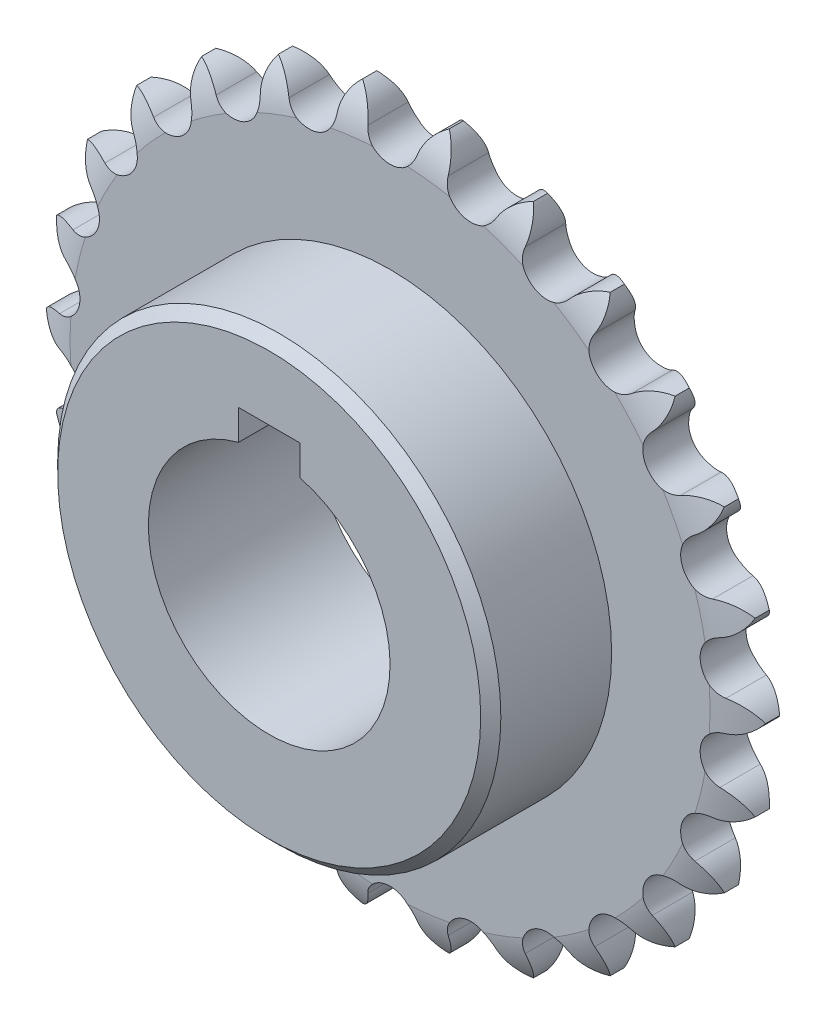
from build123d import *

# Parameters (mm, degrees)
SKETCH1_R           = 19.05
BOSS_EXTRUDE1_DEPTH = 3.6155
SKETCH2_W           = 19.05
SKETCH2_H           = 15.875
SKETCH3_W           = 9.65
SKETCH3_H           = 4.76
CUT_EXTRUDE1_DEPTH  = 85.080931
CHAMFER2_SIZE       = 1.5875
SCALE_1_SCALE       = 0.5
SCALE_2_SCALE       = 2
SCALE_3_SCALE       = 0.111111111


with BuildPart() as part:
    # Sketch1 → Boss-Extrude1 (new, symmetric)
    with BuildSketch(Plane.XY):
        with BuildLine():
            ThreePointArc((6.832203091, 56.268254805), (4.963717297, 54.655608899), (3.929721647, 52.414466562))
            ThreePointArc((3.929721647, 52.414466562), (0, 49.2633), (-3.929721647, 52.414466562))
            ThreePointArc((-3.929721647, 52.414466562), (-4.963717297, 54.655608899), (-6.832203091, 56.268254805))
            ThreePointArc((-6.832203091, 56.268254805), (-8.260462658, 54.25531154), (-8.728071806, 51.831841369))
            ThreePointArc((-8.728071806, 51.831841369), (-11.789479364, 47.831798034), (-16.359133961, 49.950953477))
            ThreePointArc((-16.359133961, 49.950953477), (-17.899424044, 51.879520935), (-20.099546463, 52.998148363))
            ThreePointArc((-20.099546463, 52.998148363), (-21.004574548, 50.701892683), (-20.87862145, 48.236937958))
            ThreePointArc((-20.87862145, 48.236937958), (-22.893797041, 43.620485829), (-27.837812873, 44.58447254))
            ThreePointArc((-27.837812873, 44.58447254), (-29.794881328, 46.088383789), (-32.198777254, 46.647982178))
            ThreePointArc((-32.198777254, 46.647982178), (-32.527976914, 44.201864118), (-31.815781507, 41.838679046))
            ThreePointArc((-31.815781507, 41.838679046), (-32.66761045, 36.87410954), (-37.698659287, 36.626904117))
            ThreePointArc((-37.698659287, 36.626904117), (-39.958768409, 37.618757301), (-42.426732148, 37.586804827))
            ThreePointArc((-42.426732148, 37.586804827), (-42.160971496, 35.132983877), (-40.903923988, 33.008908185))
            ThreePointArc((-40.903923988, 33.008908185), (-40.542901081, 27.984744038), (-45.368596652, 26.54071316))
            ThreePointArc((-45.368596652, 26.54071316), (-47.800397114, 26.962865377), (-50.188999585, 26.341219003))
            ThreePointArc((-50.188999585, 26.341219003), (-49.343723664, 24.022302317), (-47.614879086, 22.260779564))
            ThreePointArc((-47.614879086, 22.260779564), (-46.061985668, 17.469006932), (-50.401876088, 14.912072425))
            ThreePointArc((-50.401876088, 14.912072425), (-52.864040486, 14.739989724), (-55.034464796, 13.564777276))
            ThreePointArc((-55.034464796, 13.564777276), (-53.658797969, 11.515531863), (-51.558630485, 10.218935348))
            ThreePointArc((-51.558630485, 10.218935348), (-48.904115077, 5.93803464), (-52.505981689, 2.416796245))
            ThreePointArc((-52.505981689, 2.416796245), (-54.855417978, 1.660479445), (-56.681526955, 0))
            ThreePointArc((-56.681526955, 0), (-54.855417978, -1.660479445), (-52.505981689, -2.416796245))
            ThreePointArc((-52.505981689, -2.416796245), (-48.904115077, -5.93803464), (-51.558630485, -10.218935348))
            ThreePointArc((-51.558630485, -10.218935348), (-53.658797969, -11.515531863), (-55.034464796, -13.564777276))
            ThreePointArc((-55.034464796, -13.564777276), (-52.864040486, -14.739989724), (-50.401876088, -14.912072425))
            ThreePointArc((-50.401876088, -14.912072425), (-46.061985668, -17.469006932), (-47.614879086, -22.260779564))
            ThreePointArc((-47.614879086, -22.260779564), (-49.343723664, -24.022302317), (-50.188999585, -26.341219003))
            ThreePointArc((-50.188999585, -26.341219003), (-47.800397114, -26.962865377), (-45.368596652, -26.54071316))
            ThreePointArc((-45.368596652, -26.54071316), (-40.542901081, -27.984744038), (-40.903923988, -33.008908185))
            ThreePointArc((-40.903923988, -33.008908185), (-42.160971496, -35.132983877), (-42.426732148, -37.586804827))
            ThreePointArc((-42.426732148, -37.586804827), (-39.958768409, -37.618757301), (-37.698659287, -36.626904117))
            ThreePointArc((-37.698659287, -36.626904117), (-32.66761045, -36.87410954), (-31.815781507, -41.838679046))
            ThreePointArc((-31.815781507, -41.838679046), (-32.527976914, -44.201864118), (-32.198777254, -46.647982178))
            ThreePointArc((-32.198777254, -46.647982178), (-29.794881328, -46.088383789), (-27.837812873, -44.58447254))
            ThreePointArc((-27.837812873, -44.58447254), (-22.893797041, -43.620485829), (-20.87862145, -48.236937958))
            ThreePointArc((-20.87862145, -48.236937958), (-21.004574548, -50.701892683), (-20.099546463, -52.998148363))
            ThreePointArc((-20.099546463, -52.998148363), (-17.899424044, -51.879520935), (-16.359133961, -49.950953477))
            ThreePointArc((-16.359133961, -49.950953477), (-11.789479364, -47.831798034), (-8.728071806, -51.831841369))
            ThreePointArc((-8.728071806, -51.831841369), (-8.260462658, -54.25531154), (-6.832203091, -56.268254805))
            ThreePointArc((-6.832203091, -56.268254805), (-4.963717297, -54.655608899), (-3.929721647, -52.414466562))
            ThreePointArc((-3.929721647, -52.414466562), (0, -49.2633), (3.929721647, -52.414466562))
            ThreePointArc((3.929721647, -52.414466562), (4.963717297, -54.655608899), (6.832203091, -56.268254805))
            ThreePointArc((6.832203091, -56.268254805), (8.260462658, -54.25531154), (8.728071806, -51.831841369))
            ThreePointArc((8.728071806, -51.831841369), (11.789479365, -47.831798034), (16.359133961, -49.950953477))
            ThreePointArc((16.359133961, -49.950953477), (17.899424044, -51.879520935), (20.099546463, -52.998148363))
            ThreePointArc((20.099546463, -52.998148363), (21.004574548, -50.701892683), (20.87862145, -48.236937958))
            ThreePointArc((20.87862145, -48.236937958), (22.893797041, -43.620485829), (27.837812873, -44.58447254))
            ThreePointArc((27.837812873, -44.58447254), (29.794881328, -46.088383789), (32.198777254, -46.647982178))
            ThreePointArc((32.198777254, -46.647982178), (32.527976914, -44.201864118), (31.815781507, -41.838679046))
            ThreePointArc((31.815781507, -41.838679046), (32.66761045, -36.87410954), (37.698659287, -36.626904117))
            ThreePointArc((37.698659287, -36.626904117), (39.958768409, -37.618757301), (42.426732148, -37.586804827))
            ThreePointArc((42.426732148, -37.586804827), (42.160971496, -35.132983877), (40.903923988, -33.008908185))
            ThreePointArc((40.903923988, -33.008908185), (40.542901081, -27.984744038), (45.368596652, -26.54071316))
            ThreePointArc((45.368596652, -26.54071316), (47.800397114, -26.962865377), (50.188999585, -26.341219003))
            ThreePointArc((50.188999585, -26.341219003), (49.343723664, -24.022302317), (47.614879086, -22.260779564))
            ThreePointArc((47.614879086, -22.260779564), (46.061985668, -17.469006932), (50.401876088, -14.912072425))
            ThreePointArc((50.401876088, -14.912072425), (52.864040486, -14.739989724), (55.034464796, -13.564777276))
            ThreePointArc((55.034464796, -13.564777276), (53.658797969, -11.515531863), (51.558630485, -10.218935348))
            ThreePointArc((51.558630485, -10.218935348), (48.904115077, -5.93803464), (52.505981689, -2.416796245))
            ThreePointArc((52.505981689, -2.416796245), (54.855417978, -1.660479445), (56.681526955, 0))
            ThreePointArc((56.681526955, 0), (54.855417978, 1.660479445), (52.505981689, 2.416796245))
            ThreePointArc((52.505981689, 2.416796245), (48.904115077, 5.93803464), (51.558630485, 10.218935348))
            ThreePointArc((51.558630485, 10.218935348), (53.658797969, 11.515531863), (55.034464796, 13.564777276))
            ThreePointArc((55.034464796, 13.564777276), (52.864040486, 14.739989724), (50.401876088, 14.912072425))
            ThreePointArc((50.401876088, 14.912072425), (46.061985668, 17.469006932), (47.614879086, 22.260779564))
            ThreePointArc((47.614879086, 22.260779564), (49.343723664, 24.022302317), (50.188999585, 26.341219003))
            ThreePointArc((50.188999585, 26.341219003), (47.800397114, 26.962865377), (45.368596652, 26.54071316))
            ThreePointArc((45.368596652, 26.54071316), (40.542901081, 27.984744038), (40.903923988, 33.008908185))
            ThreePointArc((40.903923988, 33.008908185), (42.160971496, 35.132983877), (42.426732148, 37.586804827))
            ThreePointArc((42.426732148, 37.586804827), (39.958768409, 37.618757301), (37.698659287, 36.626904117))
            ThreePointArc((37.698659287, 36.626904117), (32.66761045, 36.87410954), (31.815781507, 41.838679046))
            ThreePointArc((31.815781507, 41.838679046), (32.527976914, 44.201864118), (32.198777254, 46.647982178))
            ThreePointArc((32.198777254, 46.647982178), (29.794881328, 46.088383789), (27.837812873, 44.58447254))
            ThreePointArc((27.837812873, 44.58447254), (22.893797041, 43.620485829), (20.87862145, 48.236937958))
            ThreePointArc((20.87862145, 48.236937958), (21.004574548, 50.701892683), (20.099546463, 52.998148363))
            ThreePointArc((20.099546463, 52.998148363), (17.899424044, 51.879520935), (16.359133961, 49.950953477))
            ThreePointArc((16.359133961, 49.950953477), (11.789479364, 47.831798034), (8.728071806, 51.831841369))
            ThreePointArc((8.728071806, 51.831841369), (8.260462658, 54.25531154), (6.832203091, 56.268254805))
        make_face()
        Circle(SKETCH1_R, mode=Mode.SUBTRACT)
    extrude(amount=BOSS_EXTRUDE1_DEPTH, both=True)

    # Sketch2 → Revolve1 (revolve)
    with BuildSketch(Plane(origin=(0, 0, 0), x_dir=(0, 0, -1), z_dir=(1, 0, 0))):
        with Locations((-13.1405, 26.9875)):
            Rectangle(SKETCH2_W, SKETCH2_H)
    revolve(axis=Axis((0, 0, 0), (0, 0, 1)))

    # Sketch3 → Cut-Extrude1 (cut, through all)
    with BuildSketch(Plane.XY.offset(22.6655)):
        with Locations((0, 20.808832709)):
            Rectangle(SKETCH3_W, SKETCH3_H)
    extrude(amount=-CUT_EXTRUDE1_DEPTH, mode=Mode.SUBTRACT)

    # Sketch4 → Cut-Revolve1 (revolve, cut)
    with BuildSketch(Plane(origin=(0, 0, 0), x_dir=(0, 0, -1), z_dir=(1, 0, 0))):
        with BuildLine():
            Line((-3.6155, 50.42), (-12.330867659, 50.42))
            Line((-12.330867659, 50.42), (-12.330867659, 56.89))
            Line((-12.330867659, 56.89), (-0.954045736, 56.89))
            ThreePointArc((-0.954045736, 56.89), (-2.739073023, 53.841877757), (-3.6155, 50.42))
        make_face()
    cut_revolve1 = revolve(axis=Axis((0, 0, 0), (0, 0, 1)), mode=Mode.SUBTRACT)

    # Mirror1: Cut-Revolve1 across plane
    add(cut_revolve1.mirror(Plane.XY), mode=Mode.SUBTRACT)

    # Chamfer2
    chamfer2_edges = [part.edges().sort_by_distance(p)[0] for p in [
        (0, -34.925, 22.6655),
    ]]
    chamfer(chamfer2_edges, length=CHAMFER2_SIZE)


with BuildPart() as part_1:
    # 缩放比例1: scaled about (-9e-09, -0.225936899, 6.41471309)
    add(part.part.scale(SCALE_1_SCALE).moved(Location((-4e-09, -0.112968449, 3.207356545))))


with BuildPart() as part_2:
    # 缩放比例2: scaled about (-9e-09, -0.225936899, 6.41471309)
    add(part_1.part.scale(SCALE_2_SCALE).moved(Location((9e-09, 0.225936899, -6.41471309))))


with BuildPart() as part_3:
    # 缩放比例3: scaled about (-9e-09, -0.225936899, 6.41471309)
    add(part_2.part.scale(SCALE_3_SCALE).moved(Location((-8e-09, -0.200832799, 5.701967191))))


solid = part_3.part
